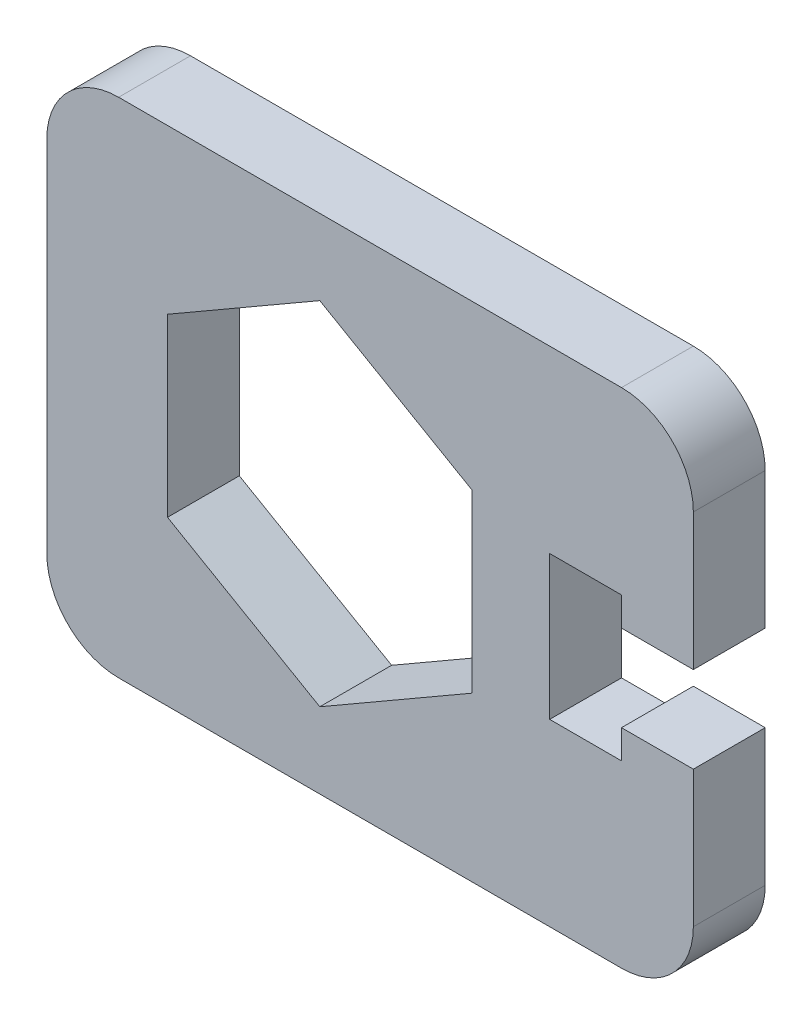
from build123d import *

# Parameters (mm, degrees)
BOSS_EXTRU_1_DEPTH = 2.5
CONG_1_R           = 5


with BuildPart() as part:
    # Esquisse1 → Boss.-Extru.1 (new body, symmetric)
    with BuildSketch(Plane.XY):
        Polygon((22.5, 3), (22.5, 17.5), (-22.5, 17.5), (-22.5, -17.5), (22.5, -17.5), (22.5, -3), (17.5, -3), (17.5, -5), (12.5, -5), (12.5, 5), (17.5, 5), (17.5, 3), align=None)
        Polygon((7.1, 6.119912853), (-3.5, 12.239825707), (-14.1, 6.119912853), (-14.1, -6.119912853), (-3.5, -12.239825707), (7.1, -6.119912853), align=None, mode=Mode.SUBTRACT)
    extrude(amount=BOSS_EXTRU_1_DEPTH, both=True)

    # Congé1
    cong_1_edges = [part.edges().sort_by_distance(p)[0] for p in [
        (-22.5, 17.5, 0),
        (22.5, 17.5, 0),
        (22.5, -17.5, 0),
        (-22.5, -17.5, 0),
    ]]
    fillet(cong_1_edges, radius=CONG_1_R)


solid = part.part
